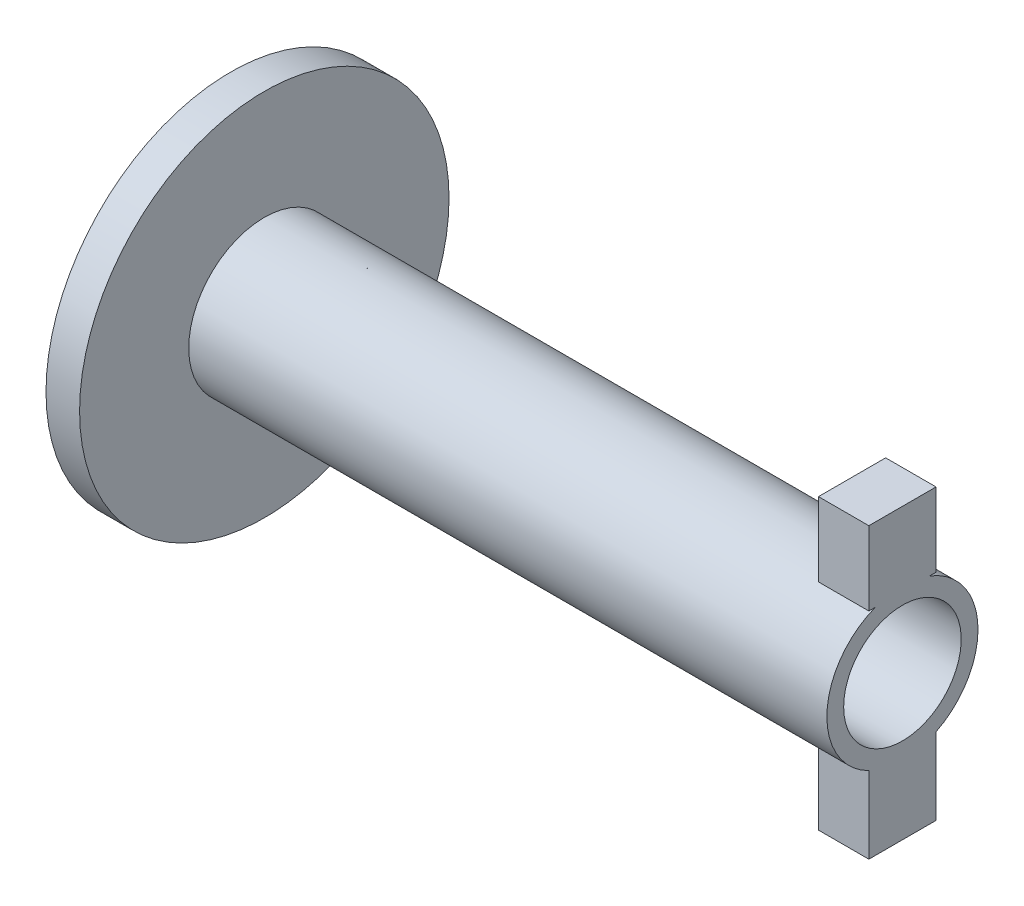
from build123d import *

# Parameters (mm, degrees)
SKETCH2_R               = 55
BOSS_EXTRUDE1_DEPTH     = 10
SKETCH3_R               = 22.5
BOSS_EXTRUDE2_DEPTH     = 190
SKETCH4_R               = 17.5
CUT_EXTRUDE1_DEPTH      = 1
CUT_EXTRUDE1_DEPTH_BACK = 201
SKETCH9_W               = 20
SKETCH9_H               = 22
BOSS_EXTRUDE3_DEPTH     = 15
SKETCH10_W              = 20
SKETCH10_H              = 23
BOSS_EXTRUDE4_DEPTH     = 15


with BuildPart() as part:
    # Sketch2 → Boss-Extrude1 (new body)
    with BuildSketch(Plane(origin=(0, 0, 0), x_dir=(0, 0, -1), z_dir=(1, 0, 0))):
        Circle(SKETCH2_R)
    extrude(amount=BOSS_EXTRUDE1_DEPTH)

    # Sketch3 → Boss-Extrude2 (add)
    with BuildSketch(Plane(origin=(10, 0, 0), x_dir=(0, 0, -1), z_dir=(1, 0, 0))):
        Circle(SKETCH3_R)
    extrude(amount=BOSS_EXTRUDE2_DEPTH)

    # Sketch4 → Cut-Extrude1 (cut, two sides)
    with BuildSketch(Plane.ZY) as cut_extrude1_sk:
        Circle(SKETCH4_R)
    extrude(amount=CUT_EXTRUDE1_DEPTH, mode=Mode.SUBTRACT)
    extrude(cut_extrude1_sk.sketch, amount=-CUT_EXTRUDE1_DEPTH_BACK, mode=Mode.SUBTRACT)

    # Sketch9 → Boss-Extrude3 (add)
    with BuildSketch(Plane(origin=(200, 0, 0), x_dir=(0, 0, -1), z_dir=(1, 0, 0))):
        with Locations((0, 32)):
            Rectangle(SKETCH9_W, SKETCH9_H)
    extrude(amount=-BOSS_EXTRUDE3_DEPTH)

    # Sketch10 → Boss-Extrude4 (add)
    with BuildSketch(Plane(origin=(200, 0, 0), x_dir=(0, 0, -1), z_dir=(1, 0, 0))):
        with Locations((0, -31.5)):
            Rectangle(SKETCH10_W, SKETCH10_H)
    extrude(amount=-BOSS_EXTRUDE4_DEPTH)


solid = part.part
